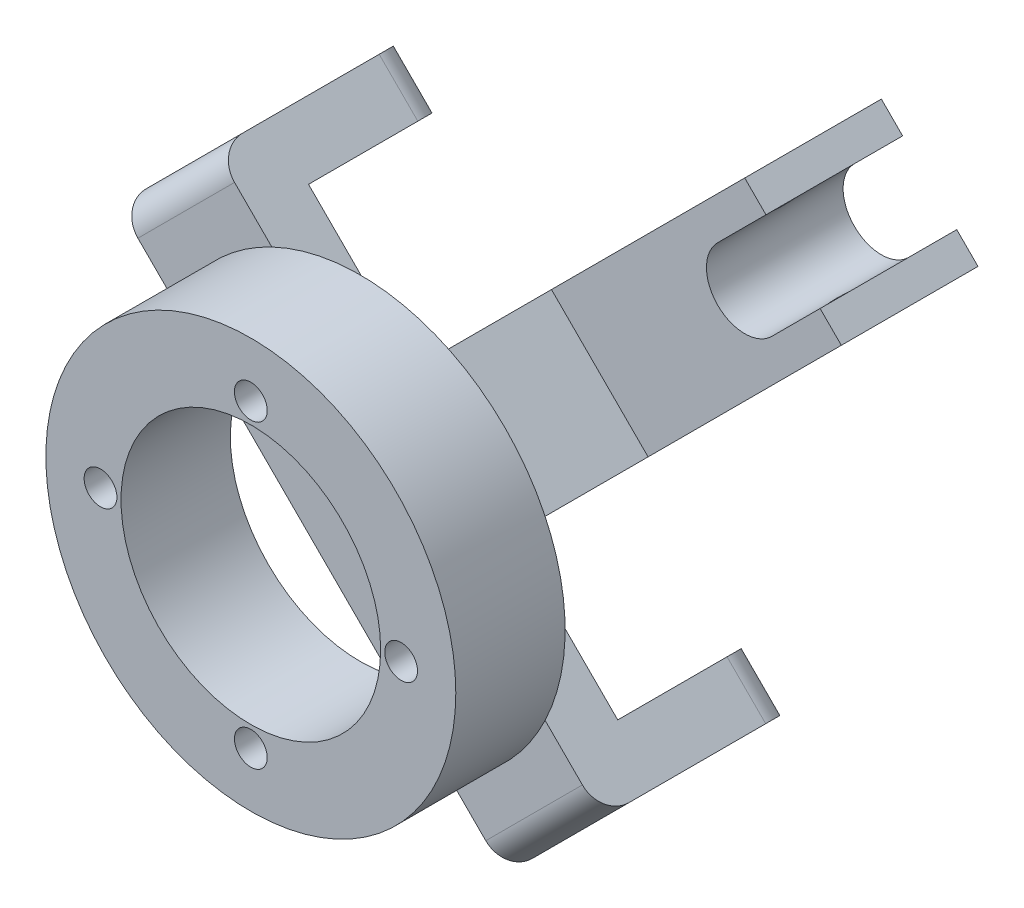
from build123d import *

# Parameters (mm, degrees)
SZKIC1_R                    = 75
DODANIE_WYCI_GNI_CIE1_DEPTH = 40
SZKIC2_R                    = 6
WYTNIJ_WYCI_GNI_CIE1_DEPTH  = 40
SZKIC3_R                    = 47.5
WYTNIJ_WYCI_GNI_CIE2_DEPTH  = 40
SZKIC4_W                    = 50
SZKIC4_H                    = 20
DODANIE_WYCI_GNI_CIE2_DEPTH = 100
SZKIC6_W                    = 50
SZKIC6_H                    = 49.999779654
DODANIE_WYCI_GNI_CIE3_DEPTH = 20
SZKIC7_R                    = 7
WYTNIJ_WYCI_GNI_CIE3_DEPTH  = 226
ZAOKR_GLENIE1_R             = 10
ZAOKR_GLENIE2_R             = 10
DODANIE_WYCI_GNI_CIE4_DEPTH = 100
SZKIC10_W                   = 50
SZKIC10_H                   = 50
DODANIE_WYCI_GNI_CIE5_DEPTH = 100
SZKIC12_R                   = 7
WYTNIJ_WYCI_GNI_CIE5_DEPTH  = 163.5
WYTNIJ_WYCI_GNI_CIE6_DEPTH  = 161


with BuildPart() as part:
    # Szkic1 → Dodanie-wyciągnięcie1 (new body)
    with BuildSketch(Plane.XY):
        Circle(SZKIC1_R)
    extrude(amount=DODANIE_WYCI_GNI_CIE1_DEPTH)

    # Szkic2 → Wytnij-wyciągnięcie1 (cut)
    with BuildSketch(Plane.XY.offset(40)):
        with Locations((-55, 0)):
            Circle(SZKIC2_R)
        with Locations((0, 55)):
            Circle(SZKIC2_R)
        with Locations((55, 0)):
            Circle(SZKIC2_R)
        with Locations((0, -55)):
            Circle(SZKIC2_R)
    extrude(amount=-WYTNIJ_WYCI_GNI_CIE1_DEPTH, mode=Mode.SUBTRACT)

    # Szkic3 → Wytnij-wyciągnięcie2 (cut)
    with BuildSketch(Plane.XY.offset(40)):
        Circle(SZKIC3_R)
    extrude(amount=-WYTNIJ_WYCI_GNI_CIE2_DEPTH, mode=Mode.SUBTRACT)

    # Szkic4 → Dodanie-wyciągnięcie2 (add, symmetric)
    with BuildSketch(Plane(origin=(0, 0, 0), x_dir=(-0.707106781, -0.707106781, 0), z_dir=(0.707106781, -0.707106781, 0))):
        with Locations((0, 10)):
            Rectangle(SZKIC4_W, SZKIC4_H)
    extrude(amount=DODANIE_WYCI_GNI_CIE2_DEPTH, both=True)

    # Szkic6 → Dodanie-wyciągnięcie3 (add)
    with BuildSketch(Plane(origin=(70.710678119, -70.710678119, 0), x_dir=(0, 0, -1), z_dir=(0.707106781, -0.707106781, 0))):
        with Locations((45, 0.000110173)):
            Rectangle(SZKIC6_W, SZKIC6_H)
    dodanie_wyci_gni_cie3 = extrude(amount=-DODANIE_WYCI_GNI_CIE3_DEPTH)

    # Lustro1: Dodanie-wyciągnięcie3 across plane
    add(dodanie_wyci_gni_cie3.mirror(Plane(origin=(0, 0, 0), x_dir=(0, 0, 1), z_dir=(0.707106781, -0.707106781, 0))))

    # Szkic7 → Wytnij-wyciągnięcie3 (cut, through all)
    with BuildSketch(Plane(origin=(-70.710678119, 70.710678119, 0), x_dir=(0, 0, 1), z_dir=(-0.707106781, 0.707106781, 0))):
        with Locations((-45, 0)):
            Circle(SZKIC7_R)
    extrude(amount=-WYTNIJ_WYCI_GNI_CIE3_DEPTH, mode=Mode.SUBTRACT)

    # Zaokrąglenie1
    zaokr_glenie1_edges = [part.edges().sort_by_distance(p)[0] for p in [
        (81.317279836, -45.961940777, -70),
        (45.962096585, -81.317124028, -70),
        (-81.317124028, 45.962096585, -70),
        (-45.961940777, 81.317279836, -70),
    ]]
    fillet(zaokr_glenie1_edges, radius=ZAOKR_GLENIE1_R)

    # Zaokrąglenie2
    zaokr_glenie2_edges = [part.edges().sort_by_distance(p)[0] for p in [
        (-70.710678119, 70.710678119, 0),
        (70.710678119, -70.710678119, 0),
    ]]
    fillet(zaokr_glenie2_edges, radius=ZAOKR_GLENIE2_R)

    # Szkic8 → Dodanie-wyciągnięcie4 (add)
    with BuildSketch(Plane(origin=(0, 0, -20), x_dir=(-1, 0, 0), z_dir=(0, 0, -1))):
        Polygon((0, 35.355339059), (35.355339059, 0), (0, -35.355339059), (-35.355339059, 0), align=None)
    extrude(amount=DODANIE_WYCI_GNI_CIE4_DEPTH)

    # Szkic10 → Dodanie-wyciągnięcie5 (add)
    with BuildSketch(Plane(origin=(17.67766953, 17.67766953, 0), x_dir=(0, 0, -1), z_dir=(0.707106781, 0.707106781, 0))):
        with Locations((95, 0)):
            Rectangle(SZKIC10_W, SZKIC10_H)
    extrude(amount=DODANIE_WYCI_GNI_CIE5_DEPTH)

    # Szkic12 → Wytnij-wyciągnięcie5 (cut, through all)
    with BuildSketch(Plane(origin=(17.67766953, -17.67766953, 0), x_dir=(0, 0, -1), z_dir=(0.707106781, -0.707106781, 0))):
        with Locations((95, 105)):
            Circle(SZKIC12_R)
    extrude(amount=-WYTNIJ_WYCI_GNI_CIE5_DEPTH, mode=Mode.SUBTRACT)

    # Szkic14 → Wytnij-wyciągnięcie6 (cut, through all)
    with BuildSketch(Plane(origin=(0, 0, -120), x_dir=(-1, 0, 0), z_dir=(0, 0, -1))):
        with BuildLine():
            Line((-80.610173055, 60.811183182), (-98.287842585, 78.488852712))
            Line((-98.287842585, 78.488852712), (-78.488852712, 98.287842585))
            Line((-78.488852712, 98.287842585), (-60.811183182, 80.610173055))
            ThreePointArc((-60.811183182, 80.610173055), (-60.811183182, 60.811183182), (-80.610173055, 60.811183182))
        make_face()
    extrude(amount=-WYTNIJ_WYCI_GNI_CIE6_DEPTH, mode=Mode.SUBTRACT)


solid = part.part
